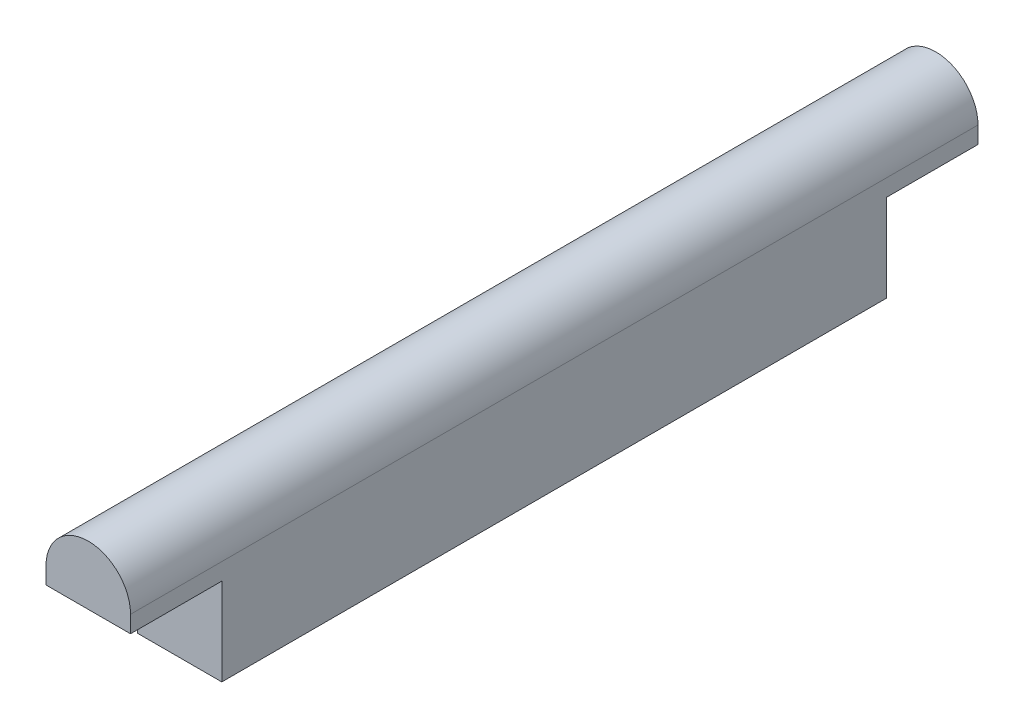
from build123d import *

# Parameters (mm, degrees)
SKETCH1_W                = 15
SKETCH1_H                = 15.5
BOSS_EXTRUDE1_DEPTH      = 118
BOSS_EXTRUDE2_DEPTH      = 16.2
BOSS_EXTRUDE2_DEPTH_BACK = 134.2


with BuildPart() as part:
    # Sketch1 → Boss-Extrude1 (new body)
    with BuildSketch(Plane.XY):
        Rectangle(SKETCH1_W, SKETCH1_H)
    extrude(amount=BOSS_EXTRUDE1_DEPTH)

    # Sketch2 → Boss-Extrude2 (add, two sides)
    with BuildSketch(Plane.XY.offset(118)) as boss_extrude2_sk:
        with BuildLine():
            Line((-7.5, 7.75), (-7.5, 10.75))
            ThreePointArc((-7.5, 10.75), (0, 18.25), (7.5, 10.75))
            Line((7.5, 10.75), (7.5, 7.75))
            Line((7.5, 7.75), (-7.5, 7.75))
        make_face()
    extrude(amount=BOSS_EXTRUDE2_DEPTH)
    extrude(boss_extrude2_sk.sketch, amount=-BOSS_EXTRUDE2_DEPTH_BACK)


solid = part.part
